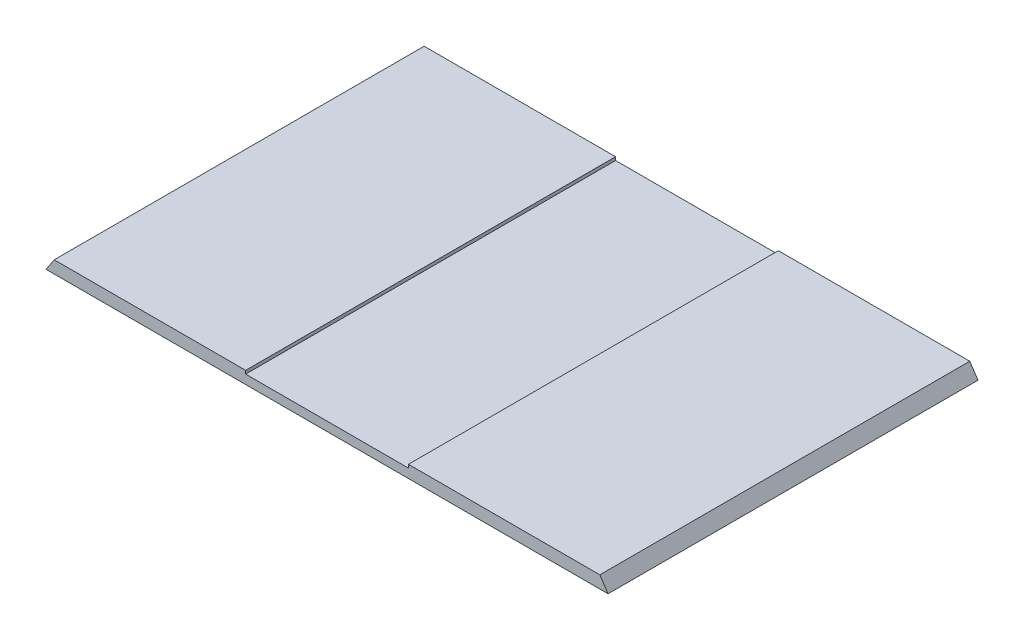
from build123d import *

# Parameters (mm, degrees)
AUFSATZ_LINEAR_AUSTRAGEN1_DEPTH = 450


with BuildPart() as part:
    # Skizze1 → Aufsatz-Linear austragen1 (new body)
    with BuildSketch(Plane.XY):
        Polygon((331.858259494, -179.367647059), (341.858259494, -194.367647059), (-341.858259494, -194.367647059), (-331.858259494, -179.367647059), (-99, -179.367647059), (-99, -183.367647059), (99, -183.367647059), (99, -179.367647059), align=None)
    extrude(amount=AUFSATZ_LINEAR_AUSTRAGEN1_DEPTH)


solid = part.part
